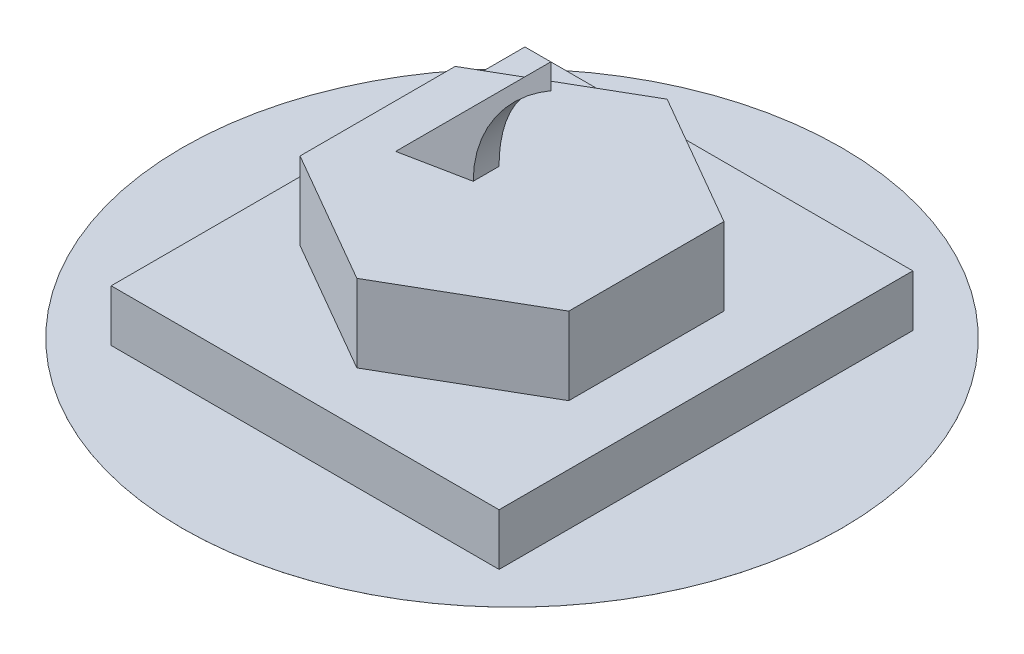
from build123d import *

# Parameters (mm, degrees)
SKETCH1_W      = 150
SKETCH1_H      = 160
EXTRUDE1_DEPTH = 20
EXTRUDE2_DEPTH = 30
EXTRUDE3_DEPTH = 50
EXTRUDE4_DEPTH = 161
SKETCH5_R      = 127.5
EXTRUDE5_DEPTH = 0.01


with BuildPart() as part:
    # Sketch1 → Extrude1 (new body)
    with BuildSketch(Plane(origin=(0, 0, 0), x_dir=(1, 0, 0), z_dir=(0, 1, 0))):
        with Locations((75, 80)):
            Rectangle(SKETCH1_W, SKETCH1_H)
    extrude(amount=EXTRUDE1_DEPTH)

    # Sketch2 → Extrude2 (add)
    with BuildSketch(Plane(origin=(0, 20, 0), x_dir=(1, 0, 0), z_dir=(0, 1, 0))):
        Polygon((75, 140), (23.038475773, 110), (23.038475773, 50), (75, 20), (126.961524227, 50), (126.961524227, 110), align=None)
    extrude(amount=EXTRUDE2_DEPTH)

    # Sketch3 → Extrude3 (add)
    with BuildSketch(Plane(origin=(0, 50, 0), x_dir=(1, 0, 0), z_dir=(0, 1, 0))):
        Polygon((40, 90), (40, 70), (90, 80), align=None)
    extrude(amount=EXTRUDE3_DEPTH)

    # Sketch4 → Extrude4 (cut, through all)
    with BuildSketch(Plane.XY):
        with BuildLine():
            Line((110, 95), (110, 50))
            Line((110, 50), (65, 50))
            ThreePointArc((65, 50), (78.180194847, 81.819805153), (110, 95))
        make_face()
        Polygon((40, 50), (90, 100), (40, 100), align=None)
    extrude(amount=-EXTRUDE4_DEPTH, mode=Mode.SUBTRACT)

    # Sketch5 → Extrude5 (add)
    with BuildSketch(Plane(origin=(0, 0, 0), x_dir=(1, 0, 0), z_dir=(0, 1, 0))):
        with Locations(Location((75, 80, 0), (0, 0, 270))):  # turned: the seam where the file's is
            Circle(SKETCH5_R)
    extrude(amount=EXTRUDE5_DEPTH)


solid = part.part
